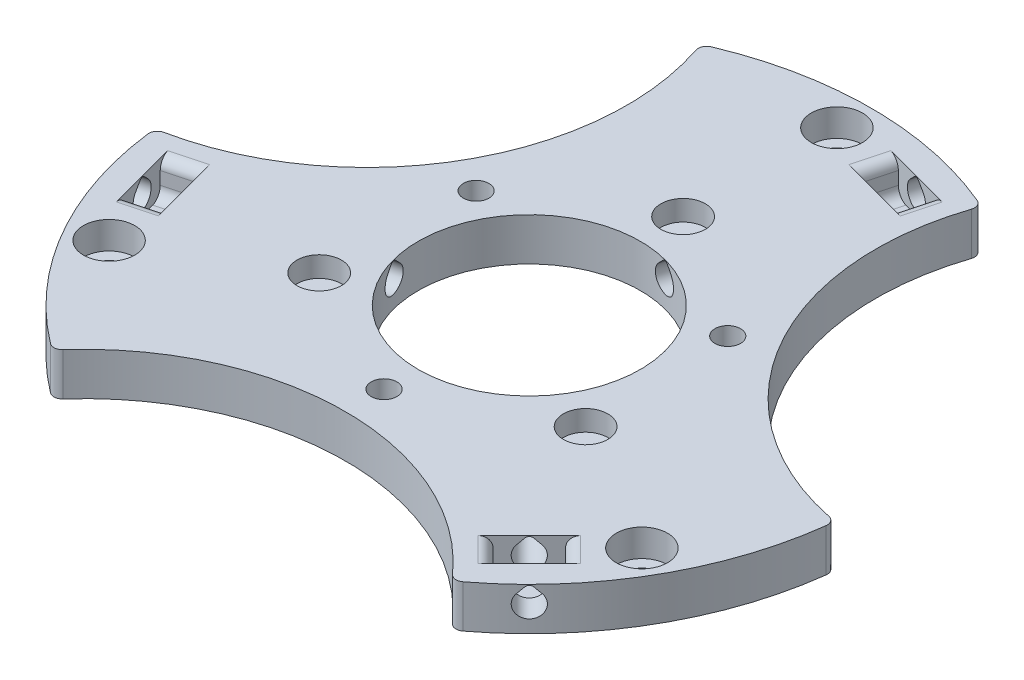
from build123d import *

# Parameters (mm, degrees)
SKETCH1_R                = 40
SKETCH1_R_2              = 13
BOSS_EXTRUDE1_DEPTH      = 5
SKETCH2_R                = 1.65
CUT_EXTRUDE1_DEPTH       = 6
CIRPATTERN1_COUNT        = 3
SKETCH3_R                = 30.47
CUT_EXTRUDE2_DEPTH       = 10
CIRPATTERN2_COUNT        = 3
FILLET1_R                = 1
SKETCH4_R                = 0.75
CUT_EXTRUDE3_DEPTH       = 10
SKETCH6_R                = 2.6
CUT_EXTRUDE4_DEPTH       = 2.4
SKETCH7_R                = 3
CUT_EXTRUDE5_DEPTH       = 3.2
CIRPATTERN3_COUNT        = 3
SKETCH8_R                = 1.5
CUT_EXTRUDE6_DEPTH       = 10
CIRPATTERN4_COUNT        = 3
CUT_EXTRUDE7_DEPTH       = 4
CUT_EXTRUDE8_START       = -25
CUT_EXTRUDE8_DEPTH       = 41.912209658
FILLET3_R                = 1.25
CIRPATTERN5_COUNT        = 3
FILLET3_OF_CIRPATTERN5_R = 1.25


with BuildPart() as part:
    # Sketch1 → Boss-Extrude1 (new body)
    with BuildSketch(Plane(origin=(0, 0, 0), x_dir=(1, 0, 0), z_dir=(0, 1, 0))):
        Circle(SKETCH1_R)
        Circle(SKETCH1_R_2, mode=Mode.SUBTRACT)
    extrude(amount=BOSS_EXTRUDE1_DEPTH)

    # Sketch2 → Cut-Extrude1 (cut, through all)
    with BuildSketch(Plane(origin=(0, 5, 0), x_dir=(1, 0, 0), z_dir=(0, 1, 0))):
        with Locations((0, 36)):
            Circle(SKETCH2_R)
    cut_extrude1 = extrude(amount=-CUT_EXTRUDE1_DEPTH, mode=Mode.SUBTRACT)

    # CirPattern1: Cut-Extrude1 ×3 about axis
    cirpattern1_axis = Axis((0, 0, 0), (0, 1, 0))
    for i in range(1, CIRPATTERN1_COUNT):
        add(cut_extrude1.rotate(cirpattern1_axis, i * 360 / CIRPATTERN1_COUNT), mode=Mode.SUBTRACT)

    # Sketch3 → Cut-Extrude2 (cut)
    with BuildSketch(Plane(origin=(0, 5, 0), x_dir=(1, 0, 0), z_dir=(0, 1, 0))):
        with Locations((45.033320997, 26)):
            Circle(SKETCH3_R)
    cut_extrude2 = extrude(amount=-CUT_EXTRUDE2_DEPTH, mode=Mode.SUBTRACT)

    # CirPattern2: Cut-Extrude2 ×3 about axis
    cirpattern2_axis = Axis((0, 0, 0), (0, 1, 0))
    for i in range(1, CIRPATTERN2_COUNT):
        add(cut_extrude2.rotate(cirpattern2_axis, i * 360 / CIRPATTERN2_COUNT), mode=Mode.SUBTRACT)

    # Fillet1
    fillet1_edges = [part.edges().sort_by_distance(p)[0] for p in [
        (16.420221954, 2.5, -36.474323996),
        (39.797802144, 2.5, 4.01683265),
        (-39.797802144, 2.5, 4.01683265),
        (-16.420221954, 2.5, -36.474323996),
        (23.377580189, 2.5, 32.457491346),
        (-23.377580189, 2.5, 32.457491346),
    ]]
    fillet(fillet1_edges, radius=FILLET1_R)

    # Sketch4 → Cut-Extrude3 (cut)
    with BuildSketch(Plane(origin=(0, 5, 0), x_dir=(1, 0, 0), z_dir=(0, 1, 0))):
        with Locations((0, 18)):
            Circle(SKETCH4_R)
    cut_extrude3 = extrude(amount=-CUT_EXTRUDE3_DEPTH, mode=Mode.SUBTRACT)

    # Sketch6 → Cut-Extrude4 (cut)
    with BuildSketch(Plane(origin=(0, 5, 0), x_dir=(1, 0, 0), z_dir=(0, 1, 0))):
        with Locations((0, 18)):
            Circle(SKETCH6_R)
    cut_extrude4 = extrude(amount=-CUT_EXTRUDE4_DEPTH, mode=Mode.SUBTRACT)

    # Sketch7 → Cut-Extrude5 (cut)
    with BuildSketch(Plane(origin=(0, 5, 0), x_dir=(1, 0, 0), z_dir=(0, 1, 0))):
        with Locations((0, 36)):
            Circle(SKETCH7_R)
    cut_extrude5 = extrude(amount=-CUT_EXTRUDE5_DEPTH, mode=Mode.SUBTRACT)

    # CirPattern3: Cut-Extrude3, Cut-Extrude4, Cut-Extrude5 ×3 about axis
    cirpattern3_axis = Axis((0, 0, 0), (0, 1, 0))
    for i in range(1, CIRPATTERN3_COUNT):
        add(cut_extrude3.rotate(cirpattern3_axis, i * 360 / CIRPATTERN3_COUNT), mode=Mode.SUBTRACT)
        add(cut_extrude4.rotate(cirpattern3_axis, i * 360 / CIRPATTERN3_COUNT), mode=Mode.SUBTRACT)
        add(cut_extrude5.rotate(cirpattern3_axis, i * 360 / CIRPATTERN3_COUNT), mode=Mode.SUBTRACT)

    # Sketch8 → Cut-Extrude6 (cut)
    with BuildSketch(Plane(origin=(0, 5, 0), x_dir=(1, 0, 0), z_dir=(0, 1, 0))):
        with Locations((14.722431864, 8.5)):
            Circle(SKETCH8_R)
    cut_extrude6 = extrude(amount=-CUT_EXTRUDE6_DEPTH, mode=Mode.SUBTRACT)

    # CirPattern4: Cut-Extrude6 ×3 about axis
    cirpattern4_axis = Axis((0, 0, 0), (0, 1, 0))
    for i in range(1, CIRPATTERN4_COUNT):
        add(cut_extrude6.rotate(cirpattern4_axis, i * 360 / CIRPATTERN4_COUNT), mode=Mode.SUBTRACT)

    # Sketch9 → Cut-Extrude7 (cut)
    with BuildSketch(Plane(origin=(0, 5, 0), x_dir=(1, 0, 0), z_dir=(0, 1, 0))):
        Polygon((5.64325101, 32.652009403), (11.438805967, 31.099095132), (12.474082148, 34.962798437), (6.67852719, 36.515712708), align=None)
    cut_extrude7 = extrude(amount=-CUT_EXTRUDE7_DEPTH, mode=Mode.SUBTRACT)

    # Sketch10 → Cut-Extrude8 (cut)
    with BuildSketch(Plane(origin=(8.541028488, 0, -31.875552268), x_dir=(-0.965925826, 0, -0.258819045), z_dir=(0.258819045, 0, -0.965925826)).offset(CUT_EXTRUDE8_START)):
        with BuildLine():
            Line((-0.376694735, 4.744625609), (-1.060660172, 4.060660172))
            ThreePointArc((-1.060660172, 4.060660172), (0, 1.5), (1.060660172, 4.060660172))
            Line((1.060660172, 4.060660172), (0.376694735, 4.744625609))
            ThreePointArc((0.376694735, 4.744625609), (0, 4.900657677), (-0.376694735, 4.744625609))
        make_face()
    cut_extrude8 = extrude(amount=CUT_EXTRUDE8_DEPTH, mode=Mode.SUBTRACT)

    # Fillet3
    fillet3_edges = [part.edges().sort_by_distance(p)[0] for p in [
        (6.1608891, 1, -34.583861055),
        (11.956444057, 1, -33.030946785),
        (6.1608891, 5, -34.583861055),
        (11.956444057, 5, -33.030946785),
    ]]
    fillet(fillet3_edges, radius=FILLET3_R)

    # CirPattern5: Cut-Extrude7, Cut-Extrude8 ×3 about axis
    cirpattern5_axis = Axis((0, 0, 0), (0, 1, 0))
    for i in range(1, CIRPATTERN5_COUNT):
        add(cut_extrude7.rotate(cirpattern5_axis, i * 360 / CIRPATTERN5_COUNT), mode=Mode.SUBTRACT)
        add(cut_extrude8.rotate(cirpattern5_axis, i * 360 / CIRPATTERN5_COUNT), mode=Mode.SUBTRACT)

    # Fillet3 of CirPattern5
    fillet3_of_cirpattern5_edges = [part.edges().sort_by_distance(p)[0] for p in [
        (-33.030946785, 1, 11.956444057),
        (-34.583861055, 1, 6.1608891),
        (-33.030946785, 5, 11.956444057),
        (-34.583861055, 5, 6.1608891),
        (26.870057685, 1, 22.627416998),
        (22.627416998, 1, 26.870057685),
        (26.870057685, 5, 22.627416998),
        (22.627416998, 5, 26.870057685),
    ]]
    fillet(fillet3_of_cirpattern5_edges, radius=FILLET3_OF_CIRPATTERN5_R)


solid = part.part
